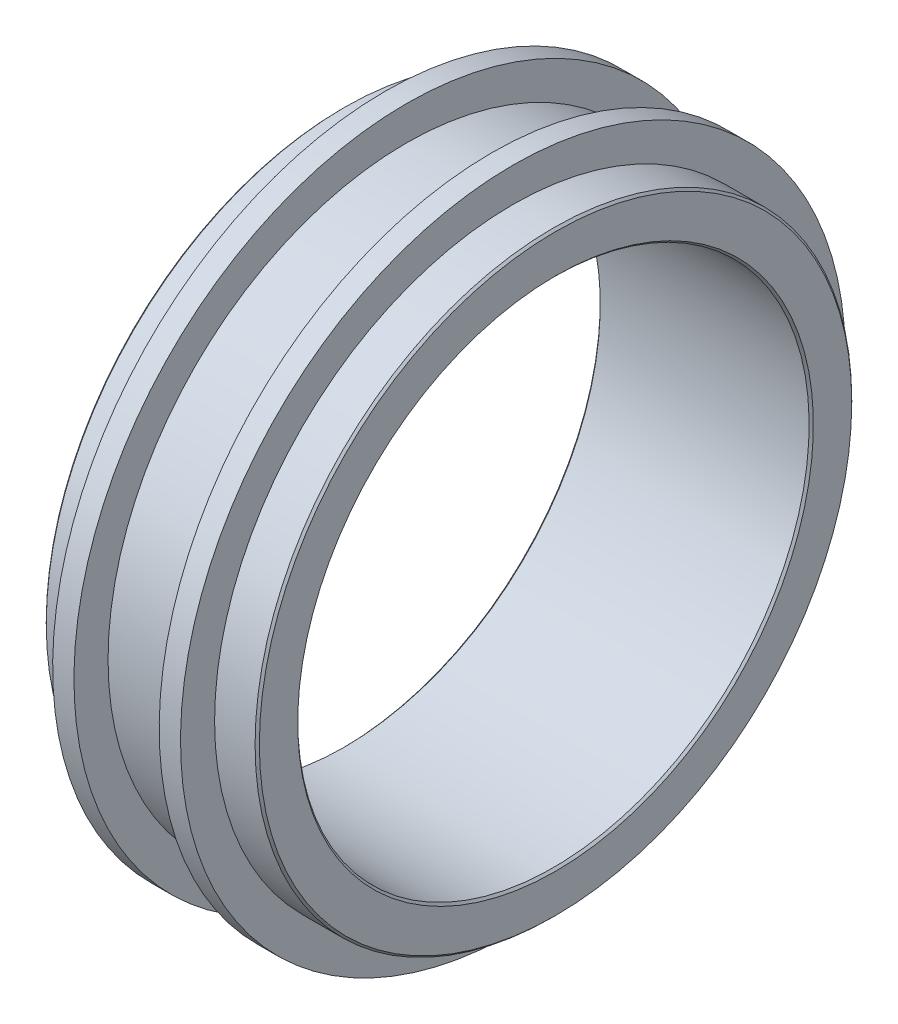
from build123d import *

# Parameters (mm, degrees)
SMUSSO1_SIZE = 0.05


with BuildPart() as part:
    # Schizzo1 → Rivoluzione1 (revolve)
    with BuildSketch(Plane.XY):
        Polygon((-4.436619718, 6), (0.563380282, 6), (0.563380282, 7), (-0.436619718, 7), (-0.436619718, 7.8), (-0.936619718, 7.8), (-0.936619718, 7), (-2.936619718, 7), (-2.936619718, 7.8), (-3.436619718, 7.8), (-3.436619718, 7), (-4.436619718, 7), align=None)
    revolve(axis=Axis((0, 0, 0), (-1, 0, 0)))

    # Smusso1
    smusso1_edges = [part.edges().sort_by_distance(p)[0] for p in [
        (0.563380282, -7, 0),
        (0.563380282, -6, 0),
        (-4.436619718, -6, 0),
        (-4.436619718, -7, 0),
    ]]
    chamfer(smusso1_edges, length=SMUSSO1_SIZE)


solid = part.part
